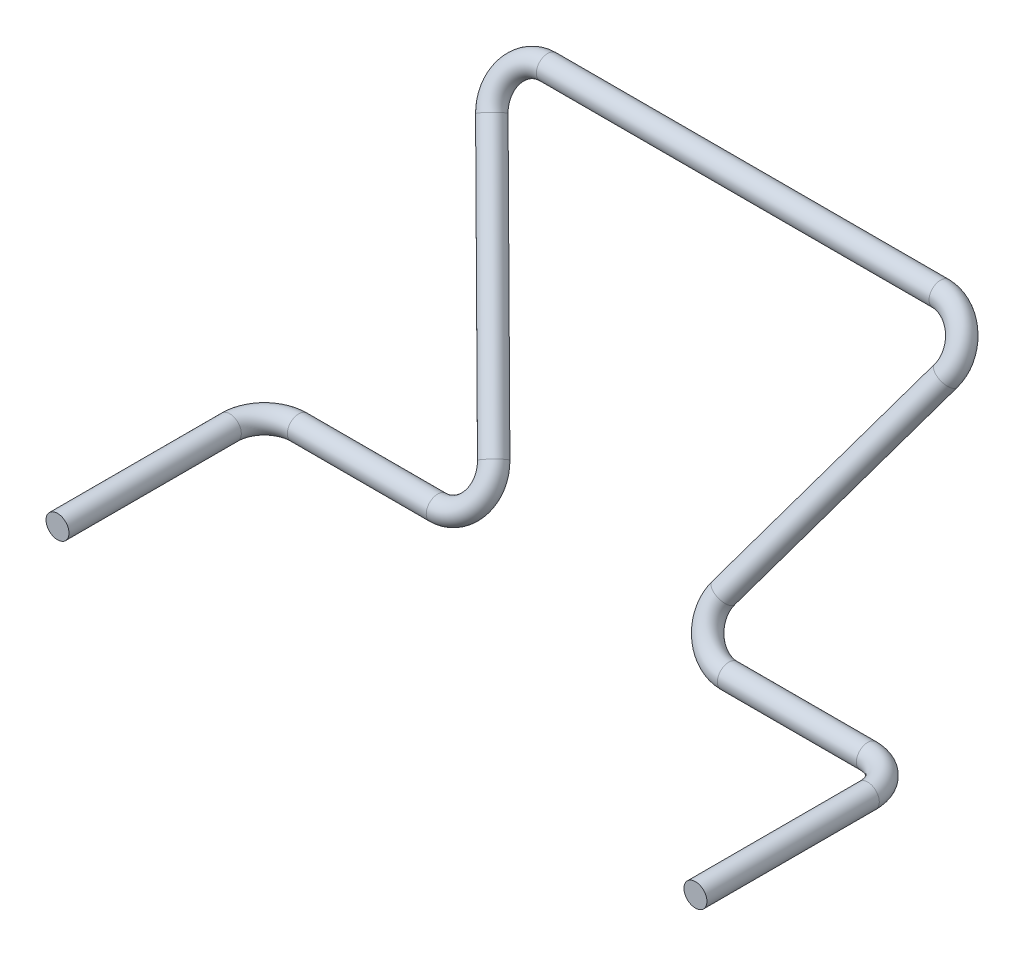
from build123d import *

# Parameters (mm, degrees)
SWEEP2_PROFILE_R = 1


with BuildPart() as part:
    # Sweep2: sweep along a curve in space
    with BuildLine() as sweep2_path:
        Line((-27.761508308, 0, 18), (-27.761508308, 0, 3))
        ThreePointArc((-27.761508308, 0, 3), (-26.882828652, 0, 0.878679656), (-24.761508308, 0, 0))
        Line((-24.761508308, 0, 0), (-12.669849025, 0, 0))
        ThreePointArc((-12.669849025, 0, 0), (-10.11010991, 1.239933795, -0.723294713), (-10, 3.773138459, -2.200997434))
        Line((-10, 3.773138459, -2.200997434), (-19.761508308, 20.226861541, -11.799002566))
        ThreePointArc((-19.761508308, 20.226861541, -11.799002566), (-19.651398399, 22.760066205, -13.276705287), (-17.091659283, 24, -14))
        Line((-17.091659283, 24, -14), (0, 24, -14))
    # Sweep2 profile (on start of the path) → Sweep2 (sweep)
    with BuildSketch(Plane(origin=(-27.761508308, 0, 18), x_dir=(0, -1, 0), z_dir=(0, 0, -1))):
        Circle(SWEEP2_PROFILE_R)
    sweep2 = sweep(path=sweep2_path.line)

    # Mirror1: Sweep2 across plane
    add(sweep2.mirror(Plane(origin=(0, 0, 0), x_dir=(0, 0, 1), z_dir=(1, 0, 0))))


solid = part.part
